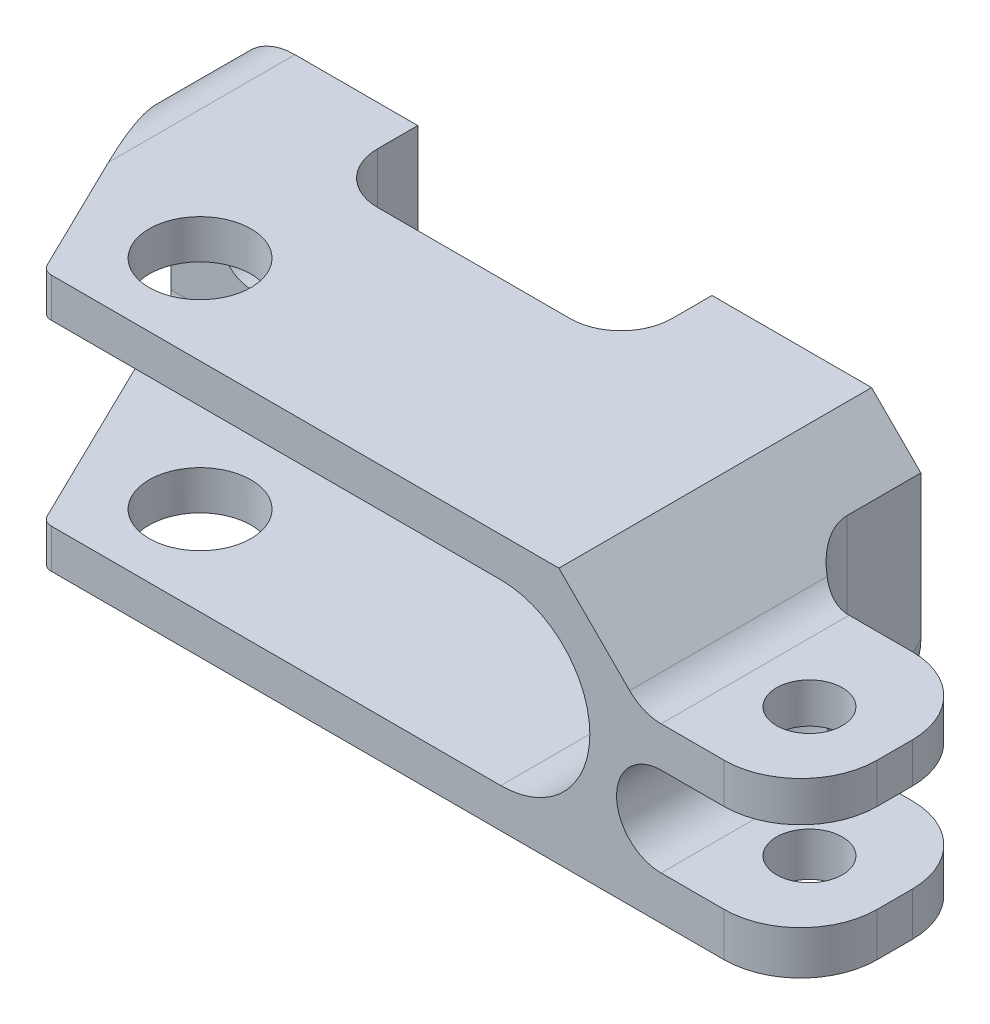
from build123d import *

# Parameters (mm, degrees)
SKETCH1_W               = 120
SKETCH1_H               = 32
EXTRUDE1_DEPTH          = 75
CUT_EXTRUDE4_START      = 8
SKETCH2_OUTSIDE_W       = 151.016
SKETCH2_OUTSIDE_H       = 63.016
CUT_EXTRUDE4_DEPTH      = 68
EXTRUDE7_DEPTH          = 36.5252
SKETCH6_R               = 6.35
SKETCH6_R_2             = 4.1021
EXTRUDE4_DEPTH          = 33
SKETCH8_OUTSIDE_W       = 151.016
SKETCH8_OUTSIDE_H       = 106.016
EXTRUDE8_DEPTH          = 33
SKETCH9_R               = 4.1021
CUT_EXTRUDE1_DEPTH      = 43.0000001
FILLET6_R               = 2
CUT_EXTRUDE2_DEPTH      = 17
CUT_EXTRUDE2_DEPTH_BACK = 17.0000001
SKETCH16_OUTSIDE_W      = 136.204
SKETCH16_OUTSIDE_H      = 58.204
CUT_EXTRUDE7_DEPTH      = 43.0000001


with BuildPart() as part:
    # Sketch1 → Extrude1 (new body)
    with BuildSketch(Plane.XY.offset(3)):
        with Locations((60, 0)):
            Rectangle(SKETCH1_W, SKETCH1_H)
    extrude(amount=EXTRUDE1_DEPTH)

    # Sketch2 outside → Cut-Extrude4 (cut, through all)
    with BuildSketch(Plane.XY.offset(3).offset(CUT_EXTRUDE4_START)):
        with Locations((60, 0)):
            Rectangle(SKETCH2_OUTSIDE_W, SKETCH2_OUTSIDE_H)
        with BuildLine():
            Line((0, 16), (82.254775894, 16))
            Line((82.254775894, 16), (91.071137947, 7.183637947))
            ThreePointArc((91.071137947, 7.183637947), (92.873715179, 5.979194347), (95, 5.55625))
            Line((95, 5.55625), (120, 5.55625))
            Line((120, 5.55625), (120, 0.55625))
            Line((120, 0.55625), (95, 0.55625))
            ThreePointArc((95, 0.55625), (89.44375, -5), (95, -10.55625))
            Line((95, -10.55625), (120, -10.55625))
            Line((120, -10.55625), (120, -16))
            Line((120, -16), (0, -16))
            Line((0, -16), (0, -11.1125))
            Line((0, -11.1125), (75, -11.1125))
            ThreePointArc((75, -11.1125), (86.1125, 0), (75, 11.1125))
            Line((75, 11.1125), (0, 11.1125))
            Line((0, 11.1125), (0, 16))
        make_face(mode=Mode.SUBTRACT)
    extrude(amount=CUT_EXTRUDE4_DEPTH, mode=Mode.SUBTRACT)

    # Sketch7 → Extrude7 (cut)
    with BuildSketch(Plane.XY):
        with BuildLine():
            Line((95, 5.55625), (120, 5.55625))
            Line((120, 5.55625), (133.084512724, 5.55625))
            Line((133.084512724, 5.55625), (133.084512724, 22.23007271))
            Line((133.084512724, 22.23007271), (82.254775894, 22.23007271))
            Line((82.254775894, 22.23007271), (82.254775894, 16))
            Line((82.254775894, 16), (91.071137947, 7.183637947))
            ThreePointArc((91.071137947, 7.183637947), (92.873715179, 5.979194347), (95, 5.55625))
        make_face()
    extrude(amount=EXTRUDE7_DEPTH, mode=Mode.SUBTRACT)

    # Sketch6 → Extrude4 (cut, through all)
    with BuildSketch(Plane(origin=(0, 16, 0), x_dir=(1, 0, 0), z_dir=(0, 1, 0))):
        with Locations((26.4, -30.9)):
            Circle(SKETCH6_R)
        with Locations((102.4, -30.9)):
            Circle(SKETCH6_R_2)
    extrude(amount=-EXTRUDE4_DEPTH, mode=Mode.SUBTRACT)

    # Sketch8 outside → Extrude8 (cut, through all)
    with BuildSketch(Plane(origin=(0, 16, 0), x_dir=(1, 0, 0), z_dir=(0, 1, 0))):
        with Locations((60, -40.5)):
            Rectangle(SKETCH8_OUTSIDE_W, SKETCH8_OUTSIDE_H)
        with BuildLine():
            Line((17.594193491, -41.157475527), (2.4, -10))
            Line((2.4, -10), (2.4, 17.886579673))
            Line((2.4, 17.886579673), (88.4, 17.886579673))
            Line((88.4, 17.886579673), (88.4, -12.2))
            ThreePointArc((88.4, -12.2), (90.259871939, -16.690128061), (94.75, -18.55))
            Line((94.75, -18.55), (102.875, -18.55))
            ThreePointArc((102.875, -18.55), (109.610192091, -21.339807909), (112.4, -28.075))
            Line((112.4, -28.075), (112.4, -32.475))
            ThreePointArc((112.4, -32.475), (109.610192091, -39.210192091), (102.875, -42))
            Line((102.875, -42), (18.942424158, -42))
            ThreePointArc((18.942424158, -42), (18.147506958, -41.772048209), (17.594193491, -41.157475527))
        make_face(mode=Mode.SUBTRACT)
    extrude(amount=-EXTRUDE8_DEPTH, mode=Mode.SUBTRACT)

    # Sketch9 → Cut-Extrude1 (cut, through all)
    with BuildSketch(Plane.XY):
        with Locations((13, 0)):
            Circle(SKETCH9_R)
        with Locations((75, 0)):
            Circle(SKETCH9_R)
    extrude(amount=CUT_EXTRUDE1_DEPTH, mode=Mode.SUBTRACT)

    # Fillet6
    fillet6_edges = [part.edges().sort_by_distance(p)[0] for p in [
        (38.943829021, 11.1125, 11),
        (86.1125, 0, 11),
        (38.943829021, -11.1125, 11),
    ]]
    fillet(fillet6_edges, radius=FILLET6_R)

    # Sketch10 → Cut-Extrude2 (cut, two sides)
    with BuildSketch(Plane(origin=(0, 0, 0), x_dir=(1, 0, 0), z_dir=(0, 1, 0))) as cut_extrude2_sk:
        with BuildLine():
            Line((32, -14.35), (56, -14.35))
            ThreePointArc((56, -14.35), (60.490128061, -12.490128061), (62.35, -8))
            Line((62.35, -8), (62.35, 20.451290564))
            Line((62.35, 20.451290564), (25.65, 20.451290564))
            Line((25.65, 20.451290564), (25.65, -8))
            ThreePointArc((25.65, -8), (27.509871939, -12.490128061), (32, -14.35))
        make_face()
    extrude(amount=CUT_EXTRUDE2_DEPTH, mode=Mode.SUBTRACT)
    extrude(cut_extrude2_sk.sketch, amount=-CUT_EXTRUDE2_DEPTH_BACK, mode=Mode.SUBTRACT)

    # Sketch16 outside → Cut-Extrude7 (cut, through all)
    with BuildSketch(Plane.XY):
        with Locations((57.4, 0)):
            Rectangle(SKETCH16_OUTSIDE_W, SKETCH16_OUTSIDE_H)
        with BuildLine():
            Line((2.4, 8.0625), (2.4, -8.0625))
            ThreePointArc((2.4, -8.0625), (4.724839924, -13.675160076), (10.3375, -16))
            Line((10.3375, -16), (122.688337856, -16))
            Line((122.688337856, -16), (122.688337856, 16))
            Line((122.688337856, 16), (10.3375, 16))
            ThreePointArc((10.3375, 16), (4.724839924, 13.675160076), (2.4, 8.0625))
        make_face(mode=Mode.SUBTRACT)
    extrude(amount=CUT_EXTRUDE7_DEPTH, mode=Mode.SUBTRACT)

    # Cut-Sweep1: sweep along a path in Sketch19
    with BuildLine(Plane.XZ.offset(16)) as cut_sweep1_path:
        ThreePointArc((88.4, 3), (90.498611985, 8.066497517), (95.565109502, 10.165109502))
    # Sketch17 → Cut-Sweep1 (sweep, cut)
    with BuildSketch(Plane(origin=(0, 0, 3), x_dir=(-1, 0, 0), z_dir=(0, 0, -1))):
        with BuildLine():
            Line((-80.4625, -16), (-80.4625, -23.337063984))
            Line((-80.4625, -23.337063984), (-92.369, -23.337063984))
            Line((-92.369, -23.337063984), (-92.369, -8.0625))
            Line((-92.369, -8.0625), (-88.4, -8.0625))
            ThreePointArc((-88.4, -8.0625), (-86.075160076, -13.675160076), (-80.4625, -16))
        make_face()
    sweep(path=cut_sweep1_path.line, mode=Mode.SUBTRACT)


solid = part.part
